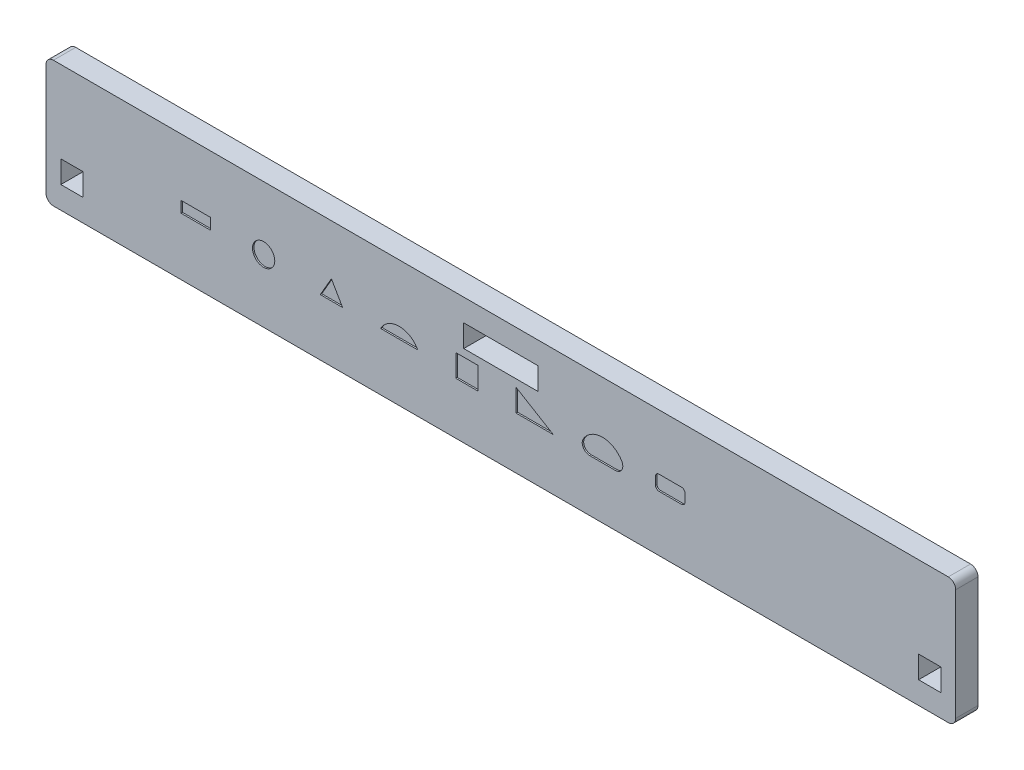
from build123d import *

# Parameters (mm, degrees)
SKETCH_1_W          = 122.5
SKETCH_1_H          = 17
SKETCH_1_W_2        = 10
SKETCH_1_H_2        = 3
SKETCH_1_W_3        = 3
EXTRUDE_1_DEPTH     = 3
FILLET_1_R          = 1
SKETCH_2_R          = 1.5
SKETCH_2_W          = 4
SKETCH_2_H          = 1.5
SKETCH_2_W_2        = 3
SKETCH_2_H_2        = 3
CUT_EXTRUDE_1_DEPTH = 0.2


with BuildPart() as part:
    # Эскиз1 → Бобышка-Вытянуть1 (new body)
    with BuildSketch(Plane.XY):
        Rectangle(SKETCH_1_W, SKETCH_1_H)
        with Locations((0, 4)):
            Rectangle(SKETCH_1_W_2, SKETCH_1_H_2, mode=Mode.SUBTRACT)
        with Locations((57.75, -4)):
            Rectangle(SKETCH_1_W_3, SKETCH_1_H_2, mode=Mode.SUBTRACT)
        with Locations((-57.75, -4)):
            Rectangle(SKETCH_1_W_3, SKETCH_1_H_2, mode=Mode.SUBTRACT)
    extrude(amount=EXTRUDE_1_DEPTH)

    # Скругление1
    fillet_1_edges = [part.edges().sort_by_distance(p)[0] for p in [
        (61.25, -8.5, 1.5),
        (-61.25, -8.5, 1.5),
        (-61.25, 8.5, 1.5),
        (61.25, 8.5, 1.5),
    ]]
    fillet(fillet_1_edges, radius=FILLET_1_R)

    # Эскиз2 → Вырез-Вытянуть1 (cut)
    with BuildSketch(Plane.XY.offset(3)):
        with Locations((-31.944049889, 0)):
            Circle(SKETCH_2_R)
        Polygon((-22.818099779, 1.732050808), (-21.318099779, -0.866025404), (-24.318099779, -0.866025404), align=None)
        with Locations((-41.07, 0)):
            Rectangle(SKETCH_2_W, SKETCH_2_H)
        with BuildLine():
            Line((-16.192149668, -0.75), (-11.192149668, -0.75))
            ThreePointArc((-11.192149668, -0.75), (-13.692149668, 0.75), (-16.192149668, -0.75))
        make_face()
        with Locations((-4.566199557, 0)):
            Rectangle(SKETCH_2_W_2, SKETCH_2_H_2)
        Polygon((2.059750554, -1.5), (2.059750554, 1.5), (7.059750554, -1.5), align=None)
        with BuildLine():
            Line((11.953649857, -1.5), (15.417751472, -1.5))
            ThreePointArc((15.417751472, -1.5), (16.283776876, -1), (16.283776876, 0))
            ThreePointArc((16.283776876, 0), (13.685700664, 1.5), (11.087624453, 0))
            ThreePointArc((11.087624453, 0), (11.087624453, -1), (11.953649857, -1.5))
        make_face()
        with BuildLine():
            Line((21.311650775, 1), (24.311650775, 1))
            ThreePointArc((24.311650775, 1), (24.665204166, 0.853553391), (24.811650775, 0.5))
            Line((24.811650775, 0.5), (24.811650775, -0.5))
            ThreePointArc((24.811650775, -0.5), (24.665204166, -0.853553391), (24.311650775, -1))
            Line((24.311650775, -1), (21.311650775, -1))
            ThreePointArc((21.311650775, -1), (20.958097384, -0.853553391), (20.811650775, -0.5))
            Line((20.811650775, -0.5), (20.811650775, 0.5))
            ThreePointArc((20.811650775, 0.5), (20.958097384, 0.853553391), (21.311650775, 1))
        make_face()
    extrude(amount=-CUT_EXTRUDE_1_DEPTH, mode=Mode.SUBTRACT)


solid = part.part
